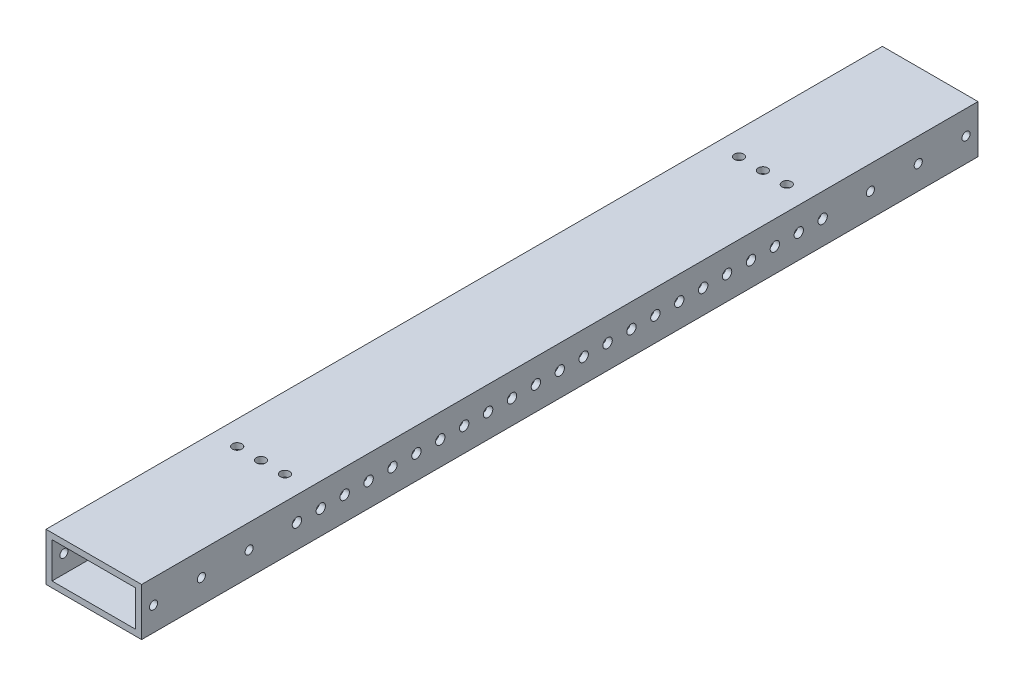
from build123d import *

# Parameters (mm, degrees)
SKETCH1_W           = 50.8
SKETCH1_H           = 25.4
SKETCH1_W_2         = 44.45
SKETCH1_H_2         = 19.05
BOSS_EXTRUDE1_DEPTH = 222.25
SKETCH3_R           = 2.15265
SKETCH3_R_2         = 2.159
CUT_EXTRUDE2_DEPTH  = 51.8
SKETCH4_R           = 2.4892
CUT_EXTRUDE3_DEPTH  = 51.8
SKETCH5_R           = 2.4892
CUT_EXTRUDE4_DEPTH  = 26.4


with BuildPart() as part:
    # Sketch1 → Boss-Extrude1 (new body, symmetric)
    with BuildSketch(Plane.XY):
        Rectangle(SKETCH1_W, SKETCH1_H)
        Rectangle(SKETCH1_W_2, SKETCH1_H_2, mode=Mode.SUBTRACT)
    extrude(amount=BOSS_EXTRUDE1_DEPTH, both=True)

    # Sketch3 → Cut-Extrude2 (cut, through all)
    with BuildSketch(Plane(origin=(25.4, 0, 0), x_dir=(0, 0, -1), z_dir=(1, 0, 0))):
        with Locations((-215.9, 0)):
            Circle(SKETCH3_R)
        with Locations((-190.5, 0)):
            Circle(SKETCH3_R)
        with Locations((-165.1, 0)):
            Circle(SKETCH3_R)
        with Locations((215.9, 0)):
            Circle(SKETCH3_R_2)
        with Locations((190.5, 0)):
            Circle(SKETCH3_R_2)
        with Locations((165.1, 0)):
            Circle(SKETCH3_R_2)
    extrude(amount=-CUT_EXTRUDE2_DEPTH, mode=Mode.SUBTRACT)

    # Sketch4 → Cut-Extrude3 (cut, through all)
    with BuildSketch(Plane(origin=(25.4, 0, 0), x_dir=(0, 0, -1), z_dir=(1, 0, 0))):
        with Locations((-139.7, 0)):
            Circle(SKETCH4_R)
        with Locations((-127, 0)):
            Circle(SKETCH4_R)
        with Locations((-114.3, 0)):
            Circle(SKETCH4_R)
        with Locations((-101.6, 0)):
            Circle(SKETCH4_R)
        with Locations((-88.9, 0)):
            Circle(SKETCH4_R)
        with Locations((-76.2, 0)):
            Circle(SKETCH4_R)
        with Locations((-63.5, 0)):
            Circle(SKETCH4_R)
        with Locations((-50.8, 0)):
            Circle(SKETCH4_R)
        with Locations((-38.1, 0)):
            Circle(SKETCH4_R)
        with Locations((-25.4, 0)):
            Circle(SKETCH4_R)
        with Locations((-12.7, 0)):
            Circle(SKETCH4_R)
        Circle(SKETCH4_R)
        with Locations((12.7, 0)):
            Circle(SKETCH4_R)
        with Locations((25.4, 0)):
            Circle(SKETCH4_R)
        with Locations((38.1, 0)):
            Circle(SKETCH4_R)
        with Locations((50.8, 0)):
            Circle(SKETCH4_R)
        with Locations((63.5, 0)):
            Circle(SKETCH4_R)
        with Locations((76.2, 0)):
            Circle(SKETCH4_R)
        with Locations((88.9, 0)):
            Circle(SKETCH4_R)
        with Locations((101.6, 0)):
            Circle(SKETCH4_R)
        with Locations((114.3, 0)):
            Circle(SKETCH4_R)
        with Locations((127, 0)):
            Circle(SKETCH4_R)
        with Locations((139.7, 0)):
            Circle(SKETCH4_R)
    extrude(amount=-CUT_EXTRUDE3_DEPTH, mode=Mode.SUBTRACT)

    # Sketch5 → Cut-Extrude4 (cut, through all)
    with BuildSketch(Plane.XZ.offset(12.7)):
        with Locations((-12.7, 133.35)):
            Circle(SKETCH5_R)
        with Locations((0, 133.35)):
            Circle(SKETCH5_R)
        with Locations((12.7, 133.35)):
            Circle(SKETCH5_R)
        with Locations((12.7, -133.35)):
            Circle(SKETCH5_R)
        with Locations((0, -133.35)):
            Circle(SKETCH5_R)
        with Locations((-12.7, -133.35)):
            Circle(SKETCH5_R)
    extrude(amount=-CUT_EXTRUDE4_DEPTH, mode=Mode.SUBTRACT)


solid = part.part
